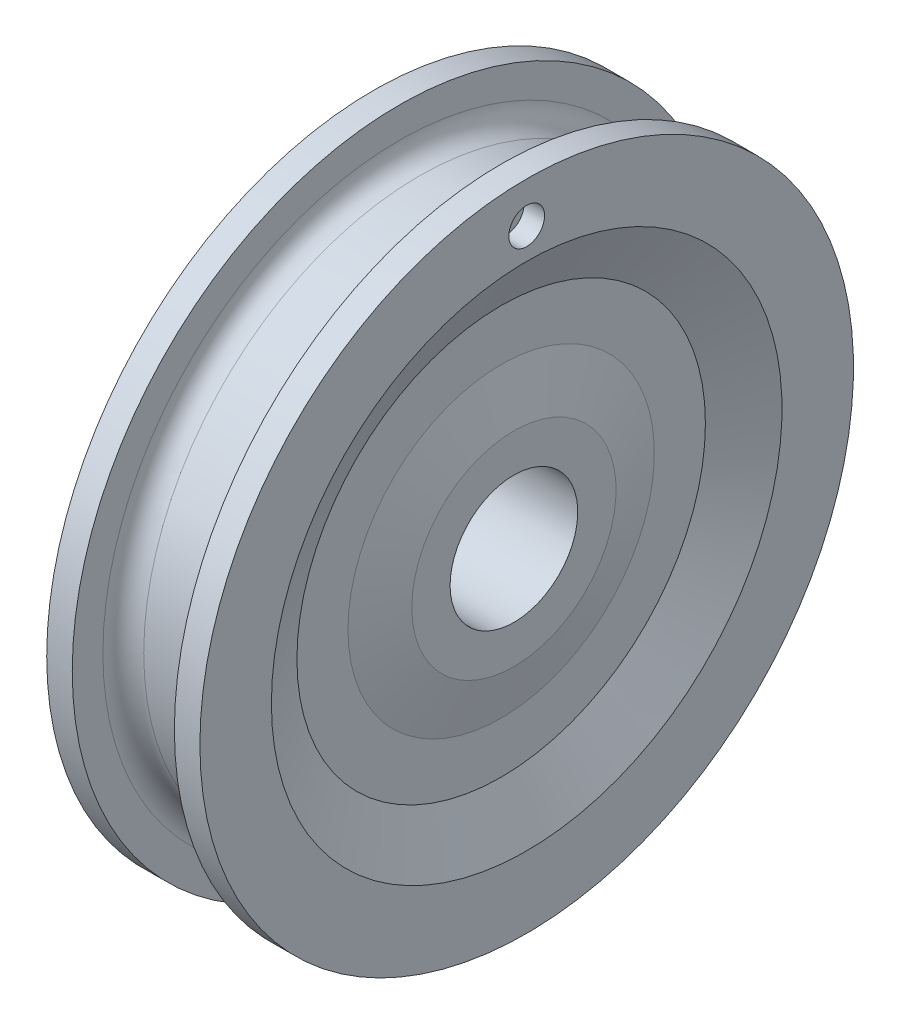
from build123d import *

# Parameters (mm, degrees)
ESBO_O4_R             = 1.75
CORTE_EXTRUS_O1_DEPTH = 2


with BuildPart() as part:
    # Esboço2 → Revolução1 (revolve)
    with BuildSketch(Plane.XY):
        with BuildLine():
            Line((1.25, 6.25), (13.75, 6.25))
            Line((13.75, 6.25), (13.75, 10))
            Line((13.75, 10), (12.5, 15))
            Line((12.5, 15), (12.5, 20))
            Line((12.5, 20), (15, 25))
            Line((15, 25), (15, 32))
            Line((15, 32), (12.5, 32))
            Line((12.5, 32), (12.5, 29))
            ThreePointArc((12.5, 29), (11.914213562, 27.585786438), (10.5, 27))
            Line((10.5, 27), (4.5, 27))
            ThreePointArc((4.5, 27), (3.085786438, 27.585786438), (2.5, 29))
            Line((2.5, 29), (2.5, 32))
            Line((2.5, 32), (0, 32))
            Line((0, 32), (0, 25))
            Line((0, 25), (2.5, 20))
            Line((2.5, 20), (2.5, 15))
            Line((2.5, 15), (1.25, 10))
            Line((1.25, 10), (1.25, 6.25))
        make_face()
    revolve(axis=Axis((0, 0, 0), (1, 0, 0)))

    # Esboço4 → Corte-extrusão1 (cut)
    with BuildSketch(Plane(origin=(15, 0, 0), x_dir=(0, 0, -1), z_dir=(1, 0, 0))):
        with Locations((0, 28)):
            Circle(ESBO_O4_R)
    extrude(amount=-CORTE_EXTRUS_O1_DEPTH, mode=Mode.SUBTRACT)


solid = part.part
